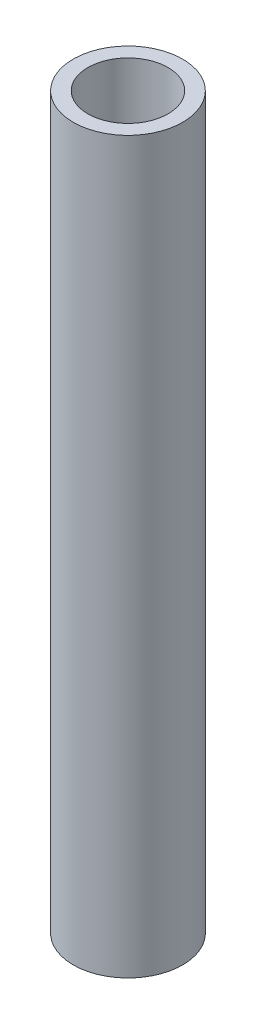
from build123d import *

# Parameters (mm, degrees)
SKETCH1_R      = 1.5
SKETCH1_R_2    = 1.1
EXTRUDE1_DEPTH = 20


with BuildPart() as part:
    # Sketch1 → Extrude1 (new body)
    with BuildSketch(Plane(origin=(0, 0, 0), x_dir=(1, 0, 0), z_dir=(0, 1, 0))):
        with Locations(Location((0, 0, 0), (0, 0, 270))):  # turned: the seam where the file's is
            Circle(SKETCH1_R)
        with Locations(Location((0, 0, 0), (0, 0, 270))):  # turned: the seam where the file's is
            Circle(SKETCH1_R_2, mode=Mode.SUBTRACT)
    extrude(amount=EXTRUDE1_DEPTH)


solid = part.part
